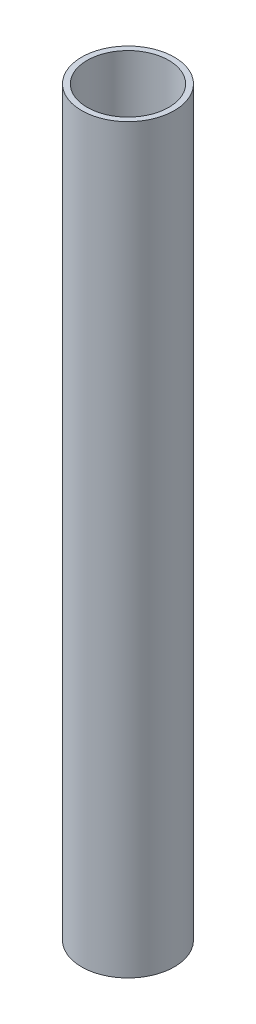
from build123d import *

# Parameters (mm, degrees)
SKETCH1_R           = 12.7
SKETCH1_R_2         = 11.176
BOSS_EXTRUDE1_DEPTH = 203.2


with BuildPart() as part:
    # Sketch1 → Boss-Extrude1 (new body)
    with BuildSketch(Plane(origin=(0, 0, 0), x_dir=(1, 0, 0), z_dir=(0, 1, 0))):
        Circle(SKETCH1_R)
        Circle(SKETCH1_R_2, mode=Mode.SUBTRACT)
    extrude(amount=BOSS_EXTRUDE1_DEPTH)


solid = part.part
